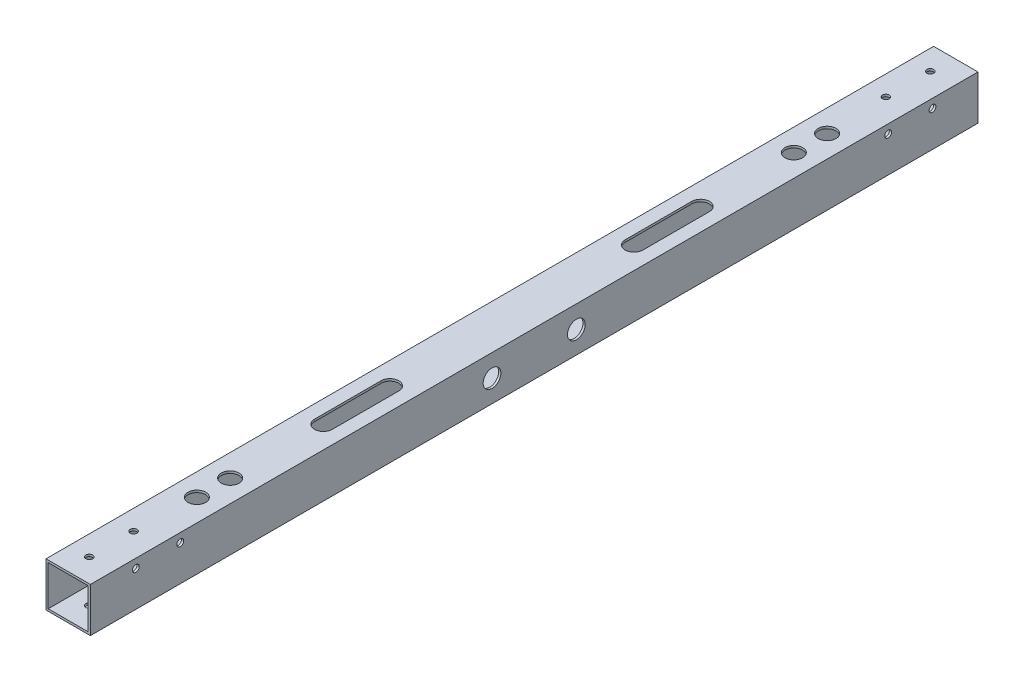
from build123d import *

# Parameters (mm, degrees)
SKETCH_1_W               = 20
SKETCH_1_H               = 20
EXTRUDE_1_DEPTH          = 200
SKETCH_2_W               = 18
SKETCH_2_H               = 18
CUT_EXTRUDE_1_DEPTH      = 201
CUT_EXTRUDE_1_DEPTH_BACK = 201
CUT_EXTRUDE_START        = -21
SKETCH_3_R               = 1.525
CUT_EXTRUDE_2_DEPTH      = 22
SKETCH_4_R               = 2.025
CUT_EXTRUDE_3_DEPTH      = 21
SKETCH_5_R               = 4
CUT_EXTRUDE_4_DEPTH      = 1
SKETCH_6_R               = 1.525
CUT_EXTRUDE_5_DEPTH      = 22
SKETCH_7_R               = 2.025
CUT_EXTRUDE_6_DEPTH      = 1
CUT_EXTRUDE_6_DEPTH_BACK = 21
SKETCH_8_R               = 4
CUT_EXTRUDE_7_DEPTH      = 3
CUT_EXTRUDE_8_DEPTH      = 1
CUT_EXTRUDE_8_DEPTH_BACK = 21


with BuildPart() as part:
    # 草图1 → 凸台-拉伸1 (new body, symmetric)
    with BuildSketch(Plane.XY):
        Rectangle(SKETCH_1_W, SKETCH_1_H)
    extrude(amount=EXTRUDE_1_DEPTH, both=True)

    # 草图2 → 切除-拉伸1 (cut, two sides)
    with BuildSketch(Plane.XY) as cut_extrude_1_sk:
        Rectangle(SKETCH_2_W, SKETCH_2_H)
    extrude(amount=CUT_EXTRUDE_1_DEPTH, mode=Mode.SUBTRACT)
    extrude(cut_extrude_1_sk.sketch, amount=-CUT_EXTRUDE_1_DEPTH_BACK, mode=Mode.SUBTRACT)

    # 草图3 → 切除-拉伸2 (cut)
    with BuildSketch(Plane(origin=(0, 10, 0), x_dir=(1, 0, 0), z_dir=(0, 1, 0)).offset(CUT_EXTRUDE_START)):
        with Locations((-1, -189.5)):
            Circle(SKETCH_3_R)
        with Locations((-1, -169.5)):
            Circle(SKETCH_3_R)
    cut_extrude_2 = extrude(amount=CUT_EXTRUDE_2_DEPTH, mode=Mode.SUBTRACT)

    # 镜向1: 切除-拉伸2 across plane
    add(cut_extrude_2.mirror(Plane.XY), mode=Mode.SUBTRACT)

    # 草图4 → 切除-拉伸3 (cut, through all)
    with BuildSketch(Plane(origin=(10, 0, 0), x_dir=(0, 0, -1), z_dir=(1, 0, 0))):
        with Locations((-19, 0)):
            Circle(SKETCH_4_R)
        with Locations((19, 0)):
            Circle(SKETCH_4_R)
    extrude(amount=-CUT_EXTRUDE_3_DEPTH, mode=Mode.SUBTRACT)

    # 草图5 → 切除-拉伸4 (cut)
    with BuildSketch(Plane(origin=(10, 0, 0), x_dir=(0, 0, -1), z_dir=(1, 0, 0))):
        with Locations((-19, 0)):
            Circle(SKETCH_5_R)
        with Locations((19, 0)):
            Circle(SKETCH_5_R)
    extrude(amount=-CUT_EXTRUDE_4_DEPTH, mode=Mode.SUBTRACT)

    # 草图6 → 切除-拉伸5 (cut)
    with BuildSketch(Plane(origin=(10, 0, 0), x_dir=(0, 0, -1), z_dir=(1, 0, 0)).offset(CUT_EXTRUDE_START)):
        with Locations((159.5, 6)):
            Circle(SKETCH_6_R)
        with Locations((179.5, 6)):
            Circle(SKETCH_6_R)
    cut_extrude_5 = extrude(amount=CUT_EXTRUDE_5_DEPTH, mode=Mode.SUBTRACT)

    # 草图7 → 切除-拉伸6 (cut, two sides)
    with BuildSketch(Plane(origin=(0, 10, 0), x_dir=(1, 0, 0), z_dir=(0, 1, 0))) as cut_extrude_6_sk:
        with Locations((0, 142)):
            Circle(SKETCH_7_R)
        with Locations((0, 127)):
            Circle(SKETCH_7_R)
        with Locations((0, -127)):
            Circle(SKETCH_7_R)
        with Locations((0, -142)):
            Circle(SKETCH_7_R)
    extrude(amount=CUT_EXTRUDE_6_DEPTH, mode=Mode.SUBTRACT)
    extrude(cut_extrude_6_sk.sketch, amount=-CUT_EXTRUDE_6_DEPTH_BACK, mode=Mode.SUBTRACT)

    # 草图8 → 切除-拉伸7 (cut)
    with BuildSketch(Plane(origin=(0, 10, 0), x_dir=(1, 0, 0), z_dir=(0, 1, 0))):
        with Locations((0, 142)):
            Circle(SKETCH_8_R)
        with Locations((0, 127)):
            Circle(SKETCH_8_R)
        with Locations((0, -127)):
            Circle(SKETCH_8_R)
        with Locations((0, -142)):
            Circle(SKETCH_8_R)
    extrude(amount=-CUT_EXTRUDE_7_DEPTH, mode=Mode.SUBTRACT)

    # 镜向2: 切除-拉伸5 across plane
    add(cut_extrude_5.mirror(Plane.XY), mode=Mode.SUBTRACT)

    # 草图9 → 切除-拉伸8 (cut, two sides)
    with BuildSketch(Plane(origin=(0, 10, 0), x_dir=(1, 0, 0), z_dir=(0, 1, 0))) as cut_extrude_8_sk:
        with BuildLine():
            Line((4, 85), (4, 55))
            ThreePointArc((4, 55), (0, 51), (-4, 55))
            Line((-4, 55), (-4, 85))
            ThreePointArc((-4, 85), (0, 89), (4, 85))
        make_face()
        with BuildLine():
            Line((4, -85), (4, -55))
            ThreePointArc((4, -55), (0, -51), (-4, -55))
            Line((-4, -55), (-4, -85))
            ThreePointArc((-4, -85), (0, -89), (4, -85))
        make_face()
    extrude(amount=CUT_EXTRUDE_8_DEPTH, mode=Mode.SUBTRACT)
    extrude(cut_extrude_8_sk.sketch, amount=-CUT_EXTRUDE_8_DEPTH_BACK, mode=Mode.SUBTRACT)


solid = part.part
